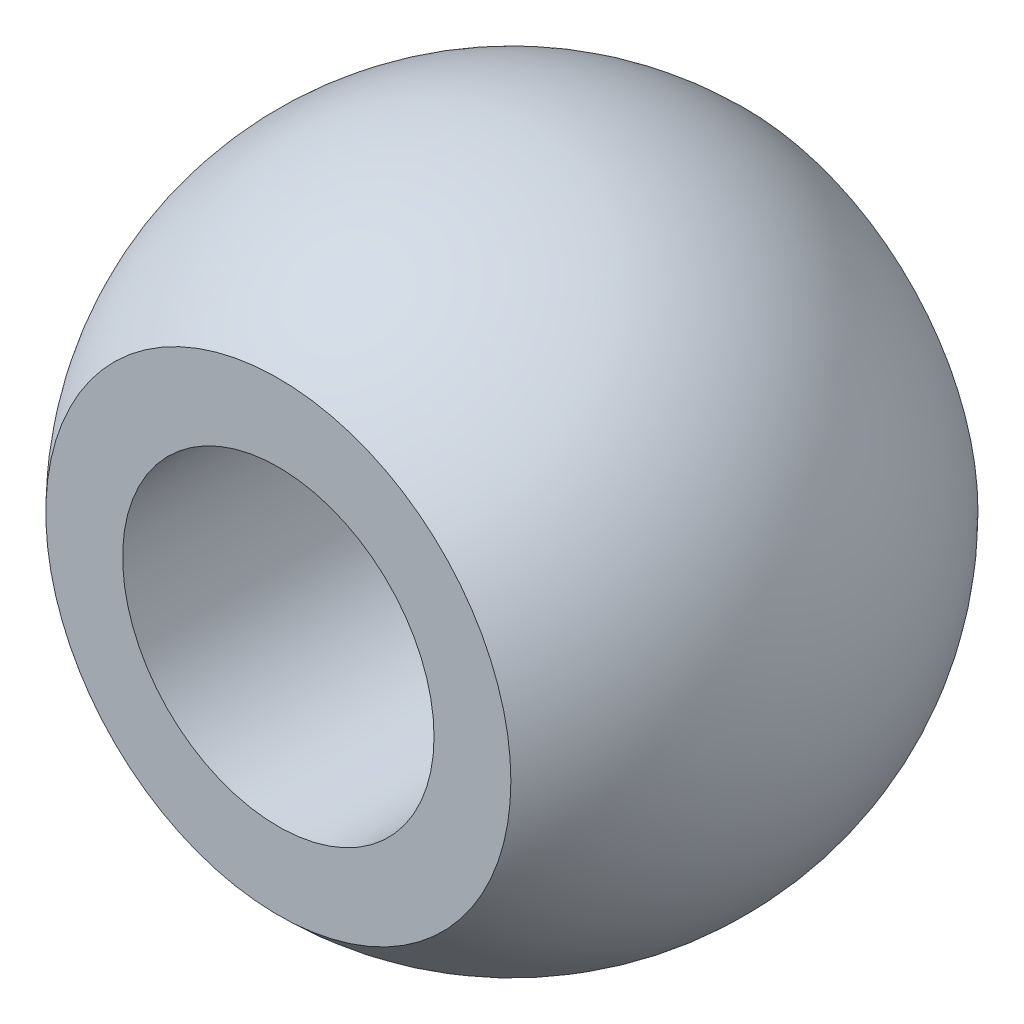
from build123d import *


with BuildPart() as part:
    # Sketch1 → Revolve1 (revolve)
    with BuildSketch(Plane(origin=(0, 0, 0), x_dir=(0, 0, -1), z_dir=(1, 0, 0))):
        with BuildLine():
            Line((-4.5, 3), (4.5, 3))
            Line((4.5, 3), (4.5, 4.480234369))
            ThreePointArc((4.5, 4.480234369), (0, 6.35), (-4.5, 4.480234369))
            Line((-4.5, 4.480234369), (-4.5, 3))
        make_face()
    revolve(axis=Axis((0, 0, -4.5), (0, 0, 1)))


solid = part.part
